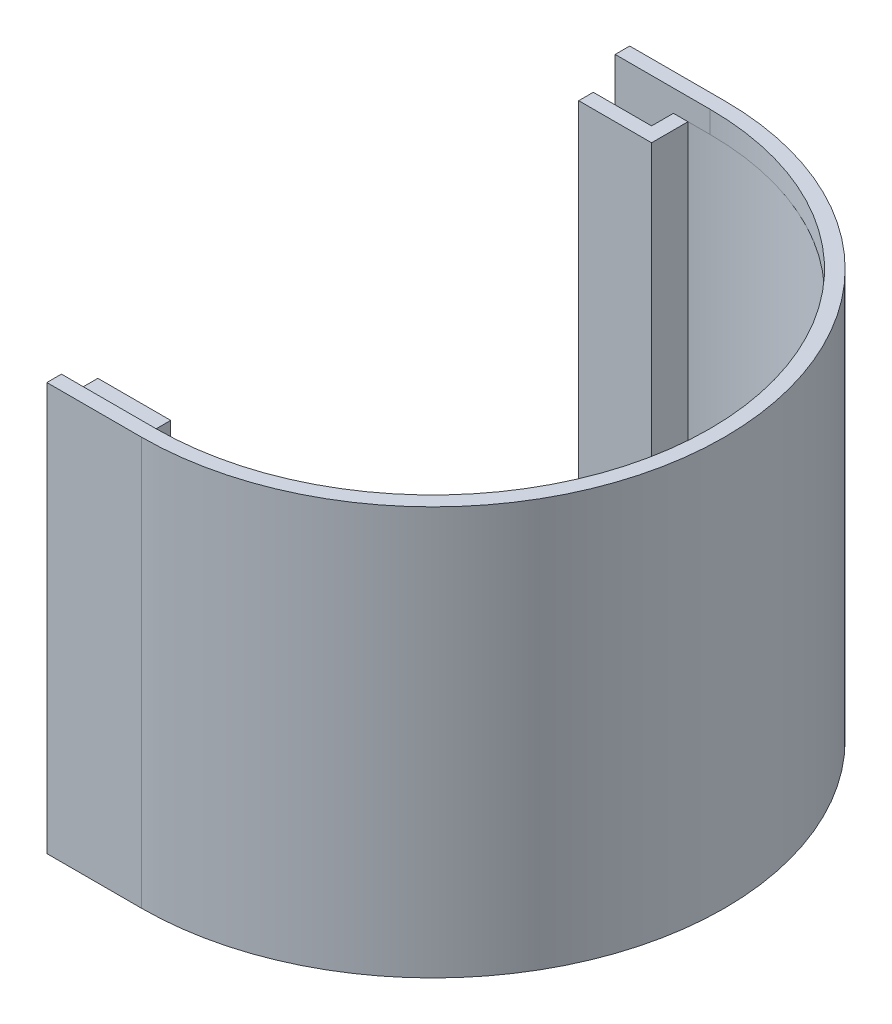
from build123d import *

# Parameters (mm, degrees)
BOSS_EXTRUDE1_DEPTH = 50
BOSS_EXTRUDE2_DEPTH = 3
BOSS_EXTRUDE3_DEPTH = 3


with BuildPart() as part:
    # Sketch6 → Boss-Extrude1 (new body)
    with BuildSketch(Plane(origin=(0, 0, 0), x_dir=(1, 0, 0), z_dir=(0, 1, 0))):
        with BuildLine():
            Line((0, 40), (-13, 40))
            Line((-13, 40), (-13, 38))
            Line((-13, 38), (-5, 38))
            Line((-5, 38), (-5, 35))
            Line((-5, 35), (-13, 35))
            Line((-13, 35), (-13, 33))
            Line((-13, 33), (-3, 33))
            Line((-3, 33), (-3, 38))
            ThreePointArc((-3, 38), (38.118237105, 0), (-3, -38))
            Line((-3, -38), (-3, -33))
            Line((-3, -33), (-13, -33))
            Line((-13, -33), (-13, -35))
            Line((-13, -35), (-5, -35))
            Line((-5, -35), (-5, -38))
            Line((-5, -38), (-13, -38))
            Line((-13, -38), (-13, -40))
            Line((-13, -40), (0, -40))
            ThreePointArc((0, -40), (40, 0), (0, 40))
        make_face()
    extrude(amount=BOSS_EXTRUDE1_DEPTH)

    # Sketch7 → Boss-Extrude2 (add)
    with BuildSketch(Plane(origin=(0, 50, 0), x_dir=(1, 0, 0), z_dir=(0, 1, 0))):
        with BuildLine():
            Line((0, -38), (-13, -38))
            Line((-13, -38), (-13, -40))
            Line((-13, -40), (0, -40))
            ThreePointArc((0, -40), (40, 0), (0, 40))
            Line((0, 40), (-13, 40))
            Line((-13, 40), (-13, 38))
            Line((-13, 38), (0, 38))
            ThreePointArc((0, 38), (38, 0), (0, -38))
        make_face()
    extrude(amount=BOSS_EXTRUDE2_DEPTH)

    # Sketch8 → Boss-Extrude3 (add)
    with BuildSketch(Plane.XZ):
        with BuildLine():
            Line((0, -40), (-13, -40))
            Line((-13, -40), (-13, -38))
            Line((-13, -38), (0, -38))
            ThreePointArc((0, -38), (38, 0), (0, 38))
            Line((0, 38), (-13, 38))
            Line((-13, 38), (-13, 40))
            Line((-13, 40), (0, 40))
            ThreePointArc((0, 40), (40, 0), (0, -40))
        make_face()
    extrude(amount=BOSS_EXTRUDE3_DEPTH)


solid = part.part
